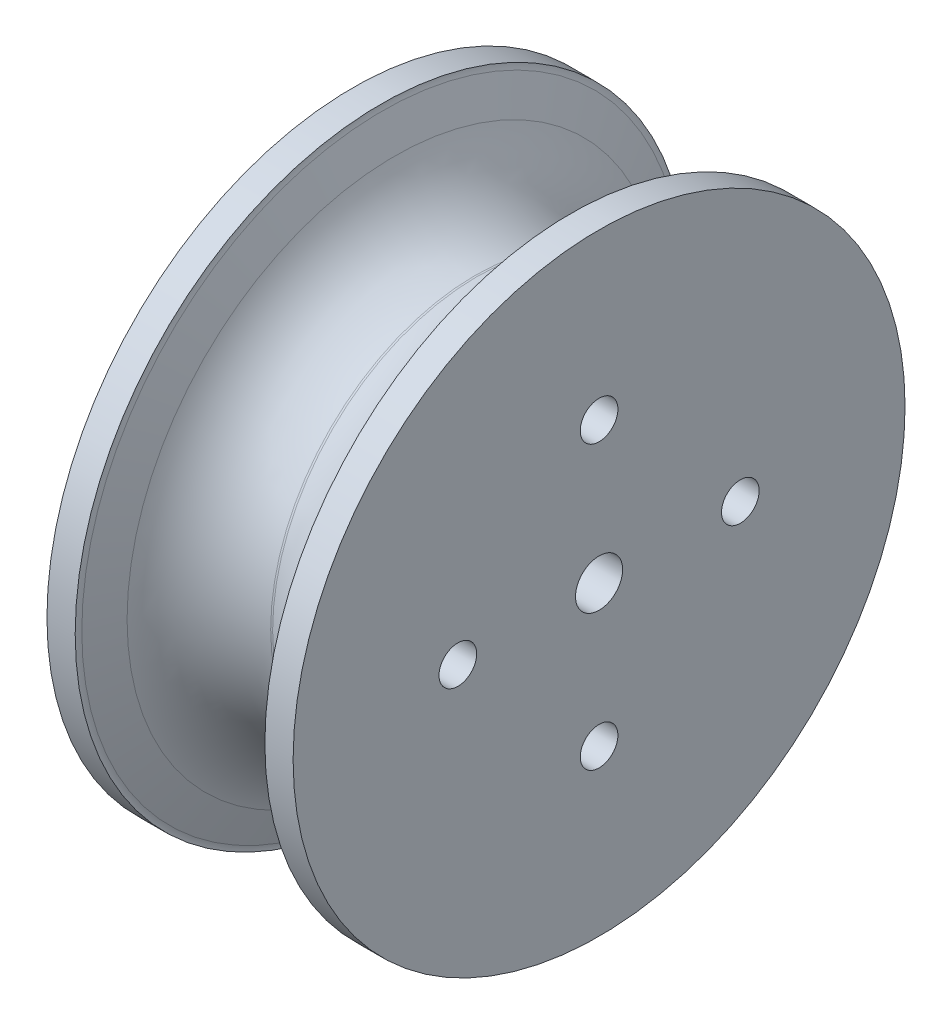
from build123d import *

# Parameters (mm, degrees)
SKETCH1_W          = 3
SKETCH1_H          = 30
SKETCH2_R          = 2
CUT_EXTRUDE1_DEPTH = 31


with BuildPart() as part:
    # Sketch1 → Revolve1 (revolve)
    with BuildSketch(Plane.XY):
        with BuildLine():
            ThreePointArc((0.101961368, 31.893841841), (0, 31.900056883), (-0.101961368, 31.893841841))
            ThreePointArc((-0.101961368, 31.893841841), (-5.309821172, 29.73045951), (-8.646594366, 25.184255434))
            Line((-8.646594366, 25.184255434), (-9.965363022, 21.693397226))
            ThreePointArc((-9.965363022, 21.693397226), (-10.046395323, 21.401631123), (-10.073702174, 21.100055213))
            Line((-10.073702174, 21.100055213), (-10.073702174, 51.100055213))
            Line((-10.073702174, 51.100055213), (10.073702174, 51.100055213))
            Line((10.073702174, 51.100055213), (10.073702174, 21.100055213))
            ThreePointArc((10.073702174, 21.100055213), (10.046395323, 21.401631123), (9.965363022, 21.693397226))
            Line((9.965363022, 21.693397226), (8.646594366, 25.184255434))
            ThreePointArc((8.646594366, 25.184255434), (5.309821172, 29.73045951), (0.101961368, 31.893841841))
        make_face()
        with Locations((-11.573702174, 36.100055213)):
            Rectangle(SKETCH1_W, SKETCH1_H)
        with Locations((11.573702174, 36.100055213)):
            Rectangle(SKETCH1_W, SKETCH1_H)
    revolve(axis=Axis((-31.343058989, 53.600055213, 0), (1, 0, 0)))

    # Sketch2 → Cut-Extrude1 (cut)
    with BuildSketch(Plane.ZY.offset(13.073702174)):
        with Locations((0, 68.600055213)):
            Circle(SKETCH2_R)
        with Locations((15, 53.600055213)):
            Circle(SKETCH2_R)
        with Locations((0, 38.600055213)):
            Circle(SKETCH2_R)
        with Locations((-15, 53.600055213)):
            Circle(SKETCH2_R)
    extrude(amount=-CUT_EXTRUDE1_DEPTH, mode=Mode.SUBTRACT)


solid = part.part
